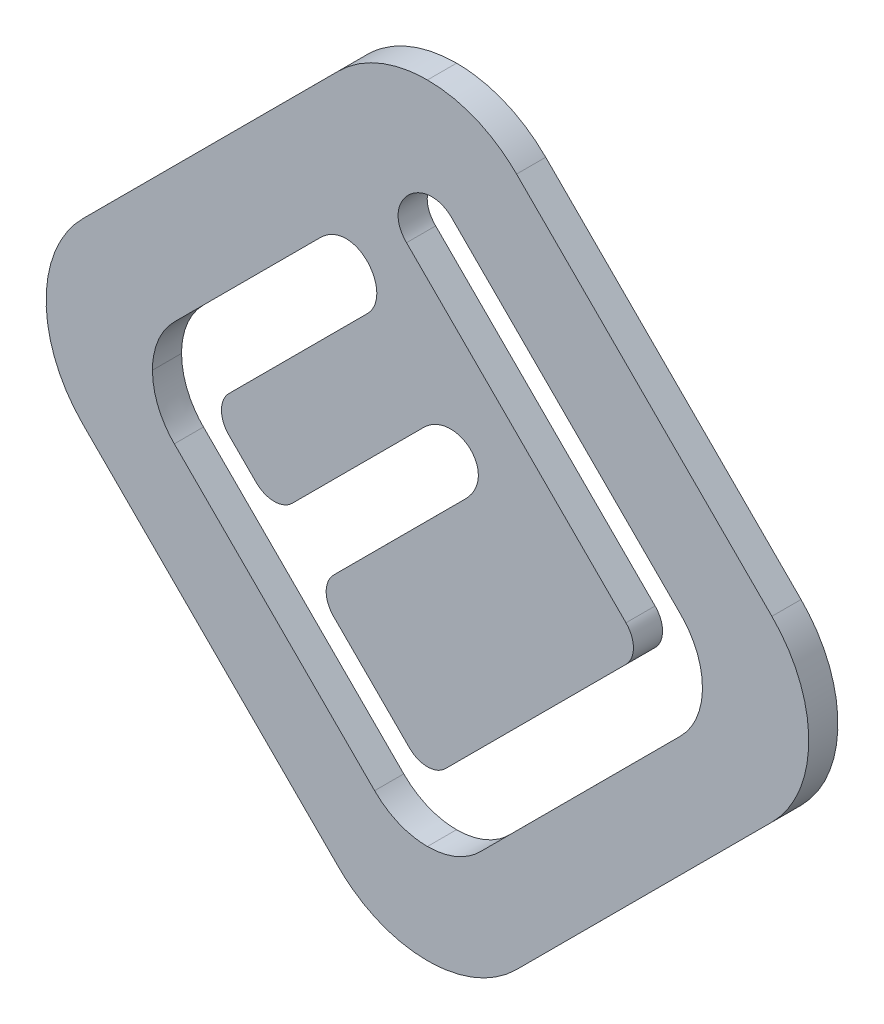
from build123d import *

# Parameters (mm, degrees)
INLAY_PROFILE_DEPTH = 1.524


with BuildPart() as part:
    # Sketch1 → Inlay Profile (new body)
    with BuildSketch(Plane.XY.offset(317.1825)):
        with BuildLine():
            Line((18.025571565, -0.367457164), (4.664168889, 12.994014038))
            add(Edge.make_bspline(
                [(4.664168889, 12.994014038), (4.356818389, 13.301283177), (4.023428442, 13.576107861), (3.303188568, 14.059147528), (2.921540553, 14.263277993), (2.327729087, 14.509301237), (2.125703276, 14.581569814), (1.713361811, 14.706360576), (1.502025353, 14.759048678), (0.864474651, 14.884719032), (0.434602166, 14.926131934), (0, 14.926131934)],
                knots=[0, 0, 0, 0, 0.25, 0.25, 0.5, 0.5, 0.625, 0.625, 0.75, 0.75, 1, 1, 1, 1], degree=3))
            add(Edge.make_bspline(
                [(0, 14.926131934), (-0.434565559, 14.926131934), (-0.864598328, 14.884737713), (-1.715362235, 14.717005142), (-2.129530035, 14.591455059), (-2.723303198, 14.345481802), (-2.91723014, 14.253710711), (-3.296979358, 14.050339945), (-3.483640779, 13.938135256), (-4.023200182, 13.576118838), (-4.356357054, 13.301389905), (-4.663566812, 12.994033668)],
                knots=[0, 0, 0, 0, 0.25, 0.25, 0.5, 0.5, 0.625, 0.625, 0.75, 0.75, 1, 1, 1, 1], degree=3))
            Line((-4.663566812, 12.994033668), (-18.025649465, -0.367432276))
            add(Edge.make_bspline(
                [(-18.025649465, -0.367432276), (-18.333467155, -0.67533686), (-18.606471867, -1.007956137), (-18.964627192, -1.543341075), (-19.075411795, -1.727908456), (-19.279353822, -2.109557241), (-19.372638179, -2.307251324), (-19.619790253, -2.906272044), (-19.743635222, -3.317359375), (-19.911015551, -4.162573597), (-19.953704554, -4.599216881), (-19.953952622, -5.459245308), (-19.912854372, -5.886970886), (-19.787519071, -6.525023338), (-19.734956892, -6.736784446), (-19.61063072, -7.149788503), (-19.538661355, -7.352219952), (-19.293631903, -7.947426043), (-19.090333968, -8.330215541), (-18.607972779, -9.052961748), (-18.333143835, -9.387372973), (-18.025264594, -9.695301528)],
                knots=[0, 0, 0, 0, 0.125, 0.125, 0.1875, 0.1875, 0.25, 0.25, 0.375, 0.375, 0.5, 0.5, 0.625, 0.625, 0.6875, 0.6875, 0.75, 0.75, 0.875, 0.875, 1, 1, 1, 1], degree=3))
            Line((-18.025264594, -9.695301528), (-4.663524615, -23.056904469))
            add(Edge.make_bspline(
                [(-4.663524615, -23.056904469), (-4.356310087, -23.364249214), (-4.023007479, -23.63909939), (-3.302884908, -24.122140042), (-2.921265042, -24.326244773), (-2.327500967, -24.572212863), (-2.12549016, -24.644461146), (-1.713179231, -24.769212535), (-1.501858849, -24.82188113), (-0.864378385, -24.94749901), (-0.434553406, -24.988892008), (0, -24.988892008)],
                knots=[0, 0, 0, 0, 0.25, 0.25, 0.5, 0.5, 0.625, 0.625, 0.75, 0.75, 1, 1, 1, 1], degree=3))
            add(Edge.make_bspline(
                [(0, -24.988892008), (0.434598725, -24.988892008), (0.864662427, -24.947480808), (1.715485434, -24.779696058), (2.129672534, -24.65411367), (2.723485659, -24.408109873), (2.917427142, -24.316331785), (3.29721076, -24.112960431), (3.48389071, -24.000763389), (4.02353835, -23.638788642), (4.356791056, -23.364119061), (4.664144191, -23.05686733)],
                knots=[0, 0, 0, 0, 0.25, 0.25, 0.5, 0.5, 0.625, 0.625, 0.75, 0.75, 1, 1, 1, 1], degree=3))
            Line((4.664144191, -23.05686733), (18.025583545, -9.695290931))
            add(Edge.make_bspline(
                [(18.025583545, -9.695290931), (18.333482821, -9.387431146), (18.606580042, -9.054852177), (18.964876906, -8.519511604), (19.07570919, -8.334956341), (19.279745495, -7.953324821), (19.373075727, -7.75563737), (19.620355994, -7.156630228), (19.744276575, -6.745539993), (19.911775941, -5.900292811), (19.954506627, -5.463624258), (19.954794901, -4.60354651), (19.913696633, -4.175791487), (19.788326474, -3.537687683), (19.735750086, -3.325922766), (19.611387505, -2.912908888), (19.539395757, -2.710472584), (19.294286623, -2.115252142), (19.090902314, -1.732430795), (18.608415217, -1.009737255), (18.333518116, -0.67535632), (18.025571565, -0.367457164)],
                knots=[0, 0, 0, 0, 0.125, 0.125, 0.1875, 0.1875, 0.25, 0.25, 0.375, 0.375, 0.5, 0.5, 0.625, 0.625, 0.6875, 0.6875, 0.75, 0.75, 0.875, 0.875, 1, 1, 1, 1], degree=3))
        make_face()
        with BuildLine():
            Line((2.764163115, -18.666741649), (13.243958907, -8.185849192))
            add(Edge.make_bspline(
                [(13.243958907, -8.185849192), (13.608833555, -7.821914197), (13.899676587, -7.388141491), (14.191534414, -6.683923004), (14.266383768, -6.43680018), (14.365551211, -5.933629733), (14.390147378, -5.678984441), (14.390147378, -5.42132701)],
                knots=[0, 0, 0, 0, 0.5, 0.5, 0.75, 0.75, 1, 1, 1, 1], degree=3))
            add(Edge.make_bspline(
                [(14.390147378, -5.42132701), (14.390147378, -4.906143502), (14.288977165, -4.393966558), (13.997180838, -3.689977029), (13.875278396, -3.462430015), (13.589364349, -3.036852796), (13.426546706, -2.839620383), (13.244193351, -2.657689678)],
                knots=[0, 0, 0, 0, 0.5, 0.5, 0.75, 0.75, 1, 1, 1, 1], degree=3))
            add(Edge.make_bspline(
                [(13.244193351, -2.657689678), (11.84504508, -1.258501699), (10.445900405, 0.14068981), (9.046761495, 1.539887083), (7.752789848, 2.833912707), (6.458822874, 4.127943003), (5.164865581, 5.421982981), (3.870908288, 6.716022958), (2.576957547, 8.010069489), (1.283039711, 9.304148919)],
                knots=[0, 0, 0, 0, 0.005936167, 0.005936167, 0.005936167, 0.011426139, 0.011426139, 0.011426139, 0.01691611, 0.01691611, 0.01691611, 0.01691611], degree=3))
            add(Edge.make_bspline(
                [(1.283039711, 9.304148919), (1.208451812, 9.37880166), (1.128215528, 9.445680851), (0.955177572, 9.562146218), (0.861064542, 9.612149298), (0.666716276, 9.688920917), (0.566349911, 9.716183545), (0.359200688, 9.74835085), (0.253130484, 9.752841938), (-0.059388996, 9.733662582), (-0.265779648, 9.677263143), (-0.64537994, 9.499967758), (-0.819554471, 9.379722795), (-1.123868056, 9.091145072), (-1.252509124, 8.924477208), (-1.398287945, 8.647032516), (-1.439236675, 8.548793299), (-1.500120392, 8.349062122), (-1.52065849, 8.24669022), (-1.538945102, 8.036179126), (-1.536277907, 7.931558062), (-1.507085794, 7.725573364), (-1.479946725, 7.622528868), (-1.364975159, 7.329677155), (-1.243195343, 7.153930867), (-1.093632727, 7.004481006)],
                knots=[0, 0, 0, 0, 0.0625, 0.0625, 0.125, 0.125, 0.1875, 0.1875, 0.25, 0.25, 0.375, 0.375, 0.5, 0.5, 0.625, 0.625, 0.6875, 0.6875, 0.75, 0.75, 0.8125, 0.8125, 0.875, 0.875, 1, 1, 1, 1], degree=3))
            add(Edge.make_bspline(
                [(-1.093632727, 7.004481006), (0.253348837, 5.656986284), (1.600507848, 4.309668958), (2.947696525, 2.962381313), (4.187919425, 1.722067304), (5.428183671, 0.481794636), (6.668468389, -0.758457558), (7.908753108, -1.998709755), (9.149059402, -3.238940377), (10.389379137, -4.479157555)],
                knots=[0, 0, 0, 0, 0.005715847, 0.005715847, 0.005715847, 0.010977861, 0.010977861, 0.010977861, 0.016239874, 0.016239874, 0.016239874, 0.016239874], degree=3))
            ThreePointArc((10.389379137, -4.479157555), (10.77999123, -5.422091507), (10.389424288, -6.36504416))
            Line((10.389424288, -6.36504416), (0.943369001, -15.811222968))
            ThreePointArc((0.943369001, -15.811222968), (0.000426035, -16.20180224), (-0.942511126, -15.811208956))
            Line((-0.942511126, -15.811208956), (-4.907243278, -11.846307125))
            ThreePointArc((-4.907243278, -11.846307125), (-5.297796208, -10.903342622), (-4.907161552, -9.960411971))
            add(Edge.make_bspline(
                [(-4.907161552, -9.960411971), (-4.017282762, -9.070649343), (-3.127409839, -8.180880848), (-2.237548499, -7.291100768), (-1.534518938, -6.588135406), (-0.831496023, -5.885163397), (-0.128489581, -5.182174915), (0.574516863, -4.47918643), (1.277525983, -3.776200612), (1.980431653, -3.073111364)],
                knots=[0, 0, 0, 0, 0.00377519, 0.00377519, 0.00377519, 0.006757755, 0.006757755, 0.006757755, 0.009740321, 0.009740321, 0.009740321, 0.009740321], degree=3))
            add(Edge.make_bspline(
                [(1.980431653, -3.073111364), (2.140804197, -2.912661242), (2.282926924, -2.73900393), (2.456044926, -2.449522576), (2.507357822, -2.3470096), (2.589643367, -2.13613991), (2.620897599, -2.027784662), (2.67933703, -1.692286826), (2.668256404, -1.461430231), (2.56455456, -1.136554805), (2.516796459, -1.034532881), (2.395068593, -0.842948012), (2.321446097, -0.754709164), (2.156381432, -0.600330836), (2.062934312, -0.532455362), (1.865547855, -0.421945587), (1.760257054, -0.378198331), (1.541383287, -0.314868209), (1.430053085, -0.29575808), (1.203867431, -0.280914383), (1.089027609, -0.285532444), (0.753475716, -0.332291796), (0.535040575, -0.408379414), (0.137984232, -0.6245314), (-0.043673421, -0.765401767), (-0.204860953, -0.926528537)],
                knots=[0, 0, 0, 0, 0.125, 0.125, 0.1875, 0.1875, 0.25, 0.25, 0.375, 0.375, 0.4375, 0.4375, 0.5, 0.5, 0.5625, 0.5625, 0.625, 0.625, 0.6875, 0.6875, 0.75, 0.75, 0.875, 0.875, 1, 1, 1, 1], degree=3))
            add(Edge.make_bspline(
                [(-0.204860953, -0.926528537), (-0.641101053, -1.362793519), (-1.077372199, -1.799027457), (-1.513647836, -2.235256899), (-2.440333949, -3.161844889), (-3.367052449, -4.088400488), (-4.293778224, -5.014948809), (-5.220504, -5.941497132), (-6.147239872, -6.868035357), (-7.073980722, -7.794568602)],
                knots=[0, 0, 0, 0, 0.001850863, 0.001850863, 0.001850863, 0.005782251, 0.005782251, 0.005782251, 0.009713639, 0.009713639, 0.009713639, 0.009713639], degree=3))
            ThreePointArc((-7.073980722, -7.794568602), (-8.017129764, -8.185036049), (-8.960086733, -7.794104987))
            Line((-8.960086733, -7.794104987), (-10.389194361, -6.363911994))
            ThreePointArc((-10.389194361, -6.363911994), (-10.779409558, -5.420973836), (-10.388672202, -4.478251932))
            add(Edge.make_bspline(
                [(-10.388672202, -4.478251932), (-9.620363184, -3.710210592), (-8.852080067, -2.942143342), (-8.083834335, -2.174038699), (-7.262017343, -1.352372632), (-6.440241976, -0.530664926), (-5.618537443, 0.291113605), (-4.796832885, 1.11289216), (-3.975193451, 1.934735858), (-3.153705857, 2.7567313)],
                knots=[0, 0, 0, 0, 0.003259091, 0.003259091, 0.003259091, 0.006745445, 0.006745445, 0.006745445, 0.0102318, 0.0102318, 0.0102318, 0.0102318], degree=3))
            add(Edge.make_bspline(
                [(-3.153705857, 2.7567313), (-3.073275327, 2.837120342), (-3.001018869, 2.923298121), (-2.874183174, 3.108172399), (-2.819145258, 3.207947086), (-2.731427392, 3.416662057), (-2.699146348, 3.523975917), (-2.657489826, 3.744452491), (-2.648280145, 3.858971027), (-2.662206408, 4.422495916), (-2.86542486, 4.865755486), (-3.274203407, 5.251671073), (-3.365231629, 5.321829449), (-3.556910695, 5.439619692), (-3.657999963, 5.488005812), (-3.978069809, 5.599529591), (-4.20753438, 5.624830423), (-4.545641744, 5.586274821), (-4.655458789, 5.56134804), (-4.869936225, 5.489914826), (-4.974382972, 5.443189754), (-5.269396668, 5.280222942), (-5.447707363, 5.138839656), (-5.608265037, 4.978375432)],
                knots=[0, 0, 0, 0, 0.0625, 0.0625, 0.125, 0.125, 0.1875, 0.1875, 0.25, 0.25, 0.5, 0.5, 0.5625, 0.5625, 0.625, 0.625, 0.75, 0.75, 0.8125, 0.8125, 0.875, 0.875, 1, 1, 1, 1], degree=3))
            add(Edge.make_bspline(
                [(-5.608265037, 4.978375432), (-6.419093367, 4.167567138), (-7.229912955, 3.356750104), (-8.04072861, 2.545929136), (-8.907975502, 1.67867656), (-9.775217571, 0.811419162), (-10.642456843, -0.055841034), (-11.509696114, -0.92310123), (-12.376932511, -1.7903643), (-13.244166976, -2.657629303)],
                knots=[0, 0, 0, 0, 0.003440011, 0.003440011, 0.003440011, 0.00711944, 0.00711944, 0.00711944, 0.010798869, 0.010798869, 0.010798869, 0.010798869], degree=3))
            add(Edge.make_bspline(
                [(-13.244166976, -2.657629303), (-13.608600195, -3.021827623), (-13.899427442, -3.455428378), (-14.191343401, -4.159425647), (-14.266223067, -4.406472325), (-14.365420486, -4.909539259), (-14.390010332, -5.164133807), (-14.390010332, -5.421738148)],
                knots=[0, 0, 0, 0, 0.5, 0.5, 0.75, 0.75, 1, 1, 1, 1], degree=3))
            add(Edge.make_bspline(
                [(-14.390010332, -5.421738148), (-14.390010332, -5.936941134), (-14.288825943, -6.449133342), (-13.997063, -7.153166102), (-13.875183954, -7.38072782), (-13.589321969, -7.806370664), (-13.426536962, -8.003645163), (-13.244218716, -8.185623942)],
                knots=[0, 0, 0, 0, 0.5, 0.5, 0.75, 0.75, 1, 1, 1, 1], degree=3))
            Line((-13.244218716, -8.185623942), (-2.764136748, -18.664986339))
            add(Edge.make_bspline(
                [(-2.764136748, -18.664986339), (-2.400035433, -19.029574977), (-1.966546507, -19.320649385), (-1.262547507, -19.612746574), (-1.015462867, -19.68766307), (-0.512378601, -19.786880045), (-0.257767564, -19.811465257), (-0.000142467, -19.811474386)],
                knots=[0, 0, 0, 0, 0.5, 0.5, 0.75, 0.75, 1, 1, 1, 1], degree=3))
            add(Edge.make_bspline(
                [(-0.000142467, -19.811474386), (0.515090813, -19.812034072), (1.027360033, -19.71098374), (1.731500271, -19.419371754), (1.959103087, -19.297532052), (2.384821027, -19.011767969), (2.582144098, -18.849033097), (2.764163115, -18.666741649)],
                knots=[0, 0, 0, 0, 0.5, 0.5, 0.75, 0.75, 1, 1, 1, 1], degree=3))
        make_face(mode=Mode.SUBTRACT)
    extrude(amount=-INLAY_PROFILE_DEPTH)


solid = part.part
